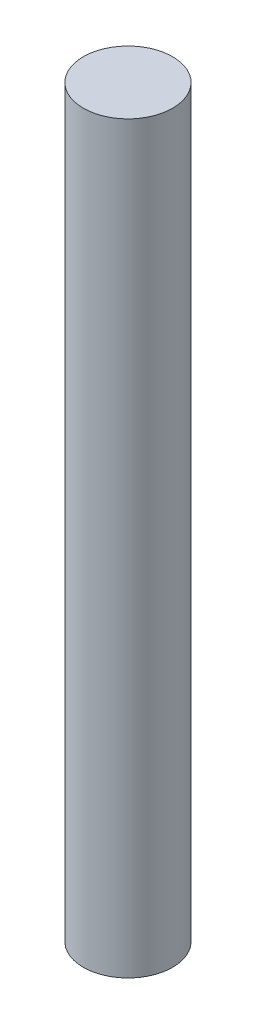
from build123d import *

# Parameters (mm, degrees)
SKETCH1_R           = 3
BOSS_EXTRUDE1_DEPTH = 50


with BuildPart() as part:
    # Sketch1 → Boss-Extrude1 (new body)
    with BuildSketch(Plane(origin=(0, 0, 0), x_dir=(1, 0, 0), z_dir=(0, 1, 0))):
        Circle(SKETCH1_R)
    extrude(amount=BOSS_EXTRUDE1_DEPTH)


solid = part.part
